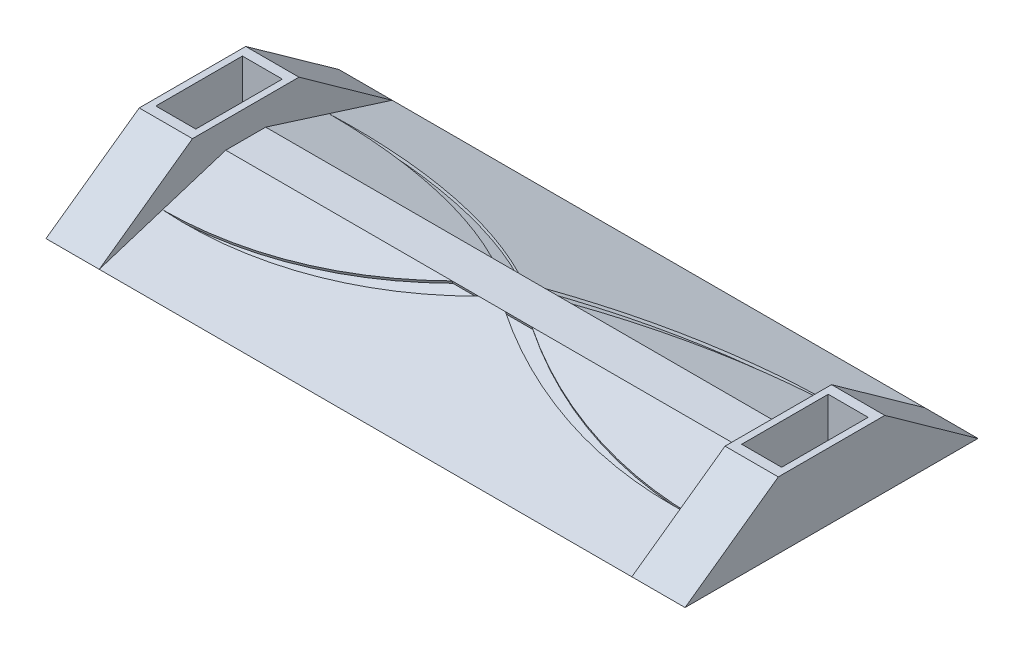
from build123d import *

# Parameters (mm, degrees)
SKETCH2_W           = 200
SKETCH2_H           = 110
BOSS_EXTRUDE2_DEPTH = 15
SKETCH3_W           = 110
SKETCH3_H           = 25
BOSS_EXTRUDE3_DEPTH = 13
CUT_EXTRUDE1_DEPTH  = 200
SKETCH8_W           = 110
SKETCH8_H           = 25
BOSS_EXTRUDE5_DEPTH = 7
SKETCH9_W           = 15
SKETCH9_H           = 32.5
CUT_EXTRUDE2_DEPTH  = 17.5
SKETCH10_W          = 110
SKETCH10_H          = 25
BOSS_EXTRUDE6_DEPTH = 20
SKETCH11_W          = 15
SKETCH11_H          = 32.5
CUT_EXTRUDE3_DEPTH  = 17.5
CUT_EXTRUDE4_DEPTH  = 20
CUT_EXTRUDE5_DEPTH  = 20
CUT_EXTRUDE11_DEPTH = 1
CUT_EXTRUDE12_DEPTH = 1


with BuildPart() as part:
    # Sketch2 → Boss-Extrude2 (new body)
    with BuildSketch(Plane(origin=(0, 0, 0), x_dir=(1, 0, 0), z_dir=(0, 1, 0))):
        Rectangle(SKETCH2_W, SKETCH2_H)
    extrude(amount=BOSS_EXTRUDE2_DEPTH)

    # Sketch3 → Boss-Extrude3 (add)
    with BuildSketch(Plane(origin=(100, 0, 0), x_dir=(0, 0, -1), z_dir=(1, 0, 0))):
        with Locations((0, 12.5)):
            Rectangle(SKETCH3_W, SKETCH3_H)
    extrude(amount=BOSS_EXTRUDE3_DEPTH)

    # Sketch6 → Cut-Extrude1 (cut)
    with BuildSketch(Plane.ZY.offset(100)):
        Polygon((-55, 0), (-7.5, 15), (-55, 15), align=None)
        Polygon((7.5, 15), (55, 0), (55, 15), align=None)
    extrude(amount=-CUT_EXTRUDE1_DEPTH, mode=Mode.SUBTRACT)

    # Sketch8 → Boss-Extrude5 (add)
    with BuildSketch(Plane(origin=(113, 0, 0), x_dir=(0, 0, -1), z_dir=(1, 0, 0))):
        with Locations((0, 12.5)):
            Rectangle(SKETCH8_W, SKETCH8_H)
    extrude(amount=BOSS_EXTRUDE5_DEPTH)

    # Sketch9 → Cut-Extrude2 (cut)
    with BuildSketch(Plane(origin=(0, 25, 0), x_dir=(1, 0, 0), z_dir=(0, 1, 0))):
        with Locations((110, 0)):
            Rectangle(SKETCH9_W, SKETCH9_H)
    extrude(amount=-CUT_EXTRUDE2_DEPTH, mode=Mode.SUBTRACT)

    # Sketch10 → Boss-Extrude6 (add)
    with BuildSketch(Plane.ZY.offset(100)):
        with Locations((0, 12.5)):
            Rectangle(SKETCH10_W, SKETCH10_H)
    extrude(amount=BOSS_EXTRUDE6_DEPTH)

    # Sketch11 → Cut-Extrude3 (cut)
    with BuildSketch(Plane(origin=(0, 25, 0), x_dir=(1, 0, 0), z_dir=(0, 1, 0))):
        with Locations((-110, 0)):
            Rectangle(SKETCH11_W, SKETCH11_H)
    extrude(amount=-CUT_EXTRUDE3_DEPTH, mode=Mode.SUBTRACT)

    # Sketch12 → Cut-Extrude4 (cut)
    with BuildSketch(Plane.ZY.offset(120)):
        Polygon((20, 25), (55, 0), (55, 25), align=None)
        Polygon((-20, 25), (-55, 25), (-55, 0), align=None)
    extrude(amount=-CUT_EXTRUDE4_DEPTH, mode=Mode.SUBTRACT)

    # Sketch13 → Cut-Extrude5 (cut)
    with BuildSketch(Plane(origin=(120, 0, 0), x_dir=(0, 0, -1), z_dir=(1, 0, 0))):
        Polygon((-20, 25), (-55, 25), (-55, 0), align=None)
        Polygon((20, 25), (55, 0), (55, 25), align=None)
    extrude(amount=-CUT_EXTRUDE5_DEPTH, mode=Mode.SUBTRACT)

    # Sketch17 → Cut-Extrude11 (cut)
    with BuildSketch(Plane(origin=(0, 15.793450882, 4.987405542), x_dir=(1, 0, 0), z_dir=(0, 0.953582665, 0.301131368))):
        with BuildLine():
            Line((-15, -2.634899469), (-5, -2.634899469))
            ThreePointArc((-5, -2.634899469), (-50.541779196, -22.5572379), (-100, -27.540973026))
            ThreePointArc((-100, -27.540973026), (-55.742204199, -21.086980727), (-15, -2.634899469))
        make_face()
        with BuildLine():
            Line((5, -2.634899469), (15, -2.634899469))
            ThreePointArc((15, -2.634899469), (55.742204199, -21.086980727), (100, -27.540973026))
            ThreePointArc((100, -27.540973026), (50.541779196, -22.5572379), (5, -2.634899469))
        make_face()
    extrude(amount=-CUT_EXTRUDE11_DEPTH, mode=Mode.SUBTRACT)

    # Sketch18 → Cut-Extrude12 (cut)
    with BuildSketch(Plane(origin=(0, 15.793450882, -4.987405542), x_dir=(1, 0, 0), z_dir=(0, 0.953582665, -0.301131368))):
        with BuildLine():
            Line((15, 2.634899469), (5, 2.634899469))
            ThreePointArc((5, 2.634899469), (50.541779196, 22.5572379), (100, 27.540973026))
            ThreePointArc((100, 27.540973026), (55.742204199, 21.086980727), (15, 2.634899469))
        make_face()
        with BuildLine():
            Line((-5, 2.634899469), (-15, 2.634899469))
            ThreePointArc((-15, 2.634899469), (-55.742204199, 21.086980727), (-100, 27.540973026))
            ThreePointArc((-100, 27.540973026), (-50.541779196, 22.5572379), (-5, 2.634899469))
        make_face()
    extrude(amount=-CUT_EXTRUDE12_DEPTH, mode=Mode.SUBTRACT)


solid = part.part
